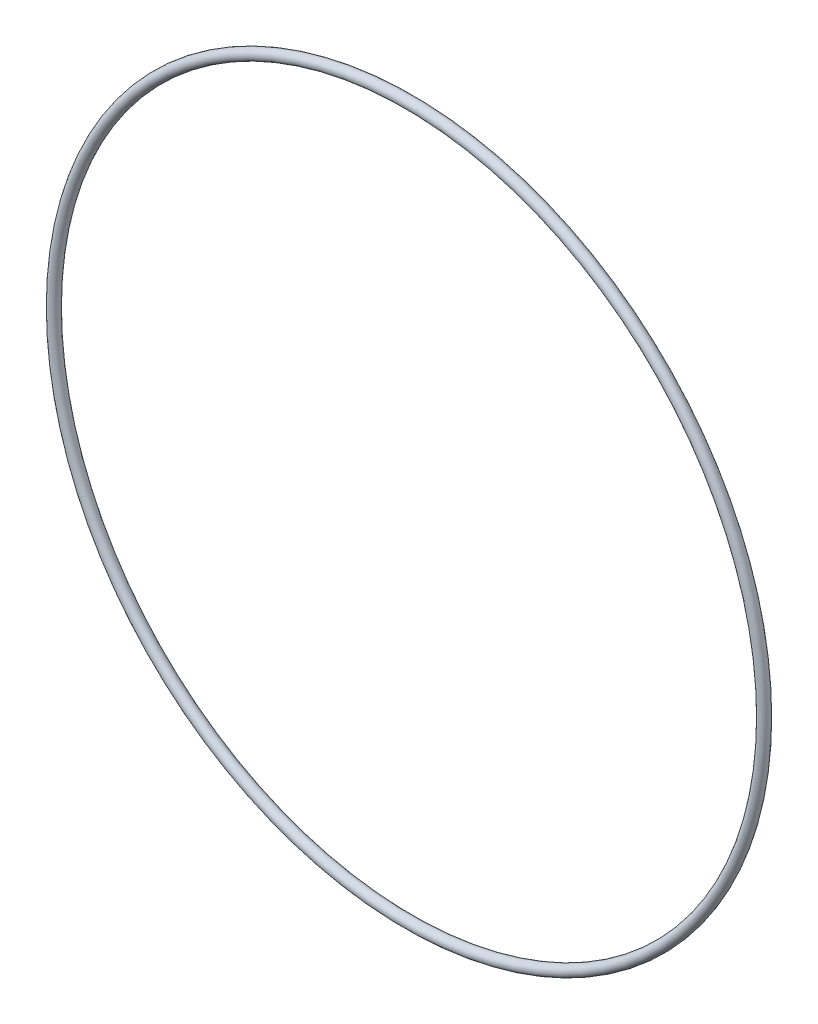
from build123d import *

# Parameters (mm, degrees)
SKETCH1_R = 1.3081


with BuildPart() as part:
    # Sketch1 → Revolve1 (revolve)
    with BuildSketch(Plane(origin=(0, 0, 0), x_dir=(0, -1, 0), z_dir=(1, 0, 0))):
        with Locations((86.868, 0)):
            Circle(SKETCH1_R)
    revolve(axis=Axis((0, 0, 1.3081), (0, 0, -1)))


solid = part.part
